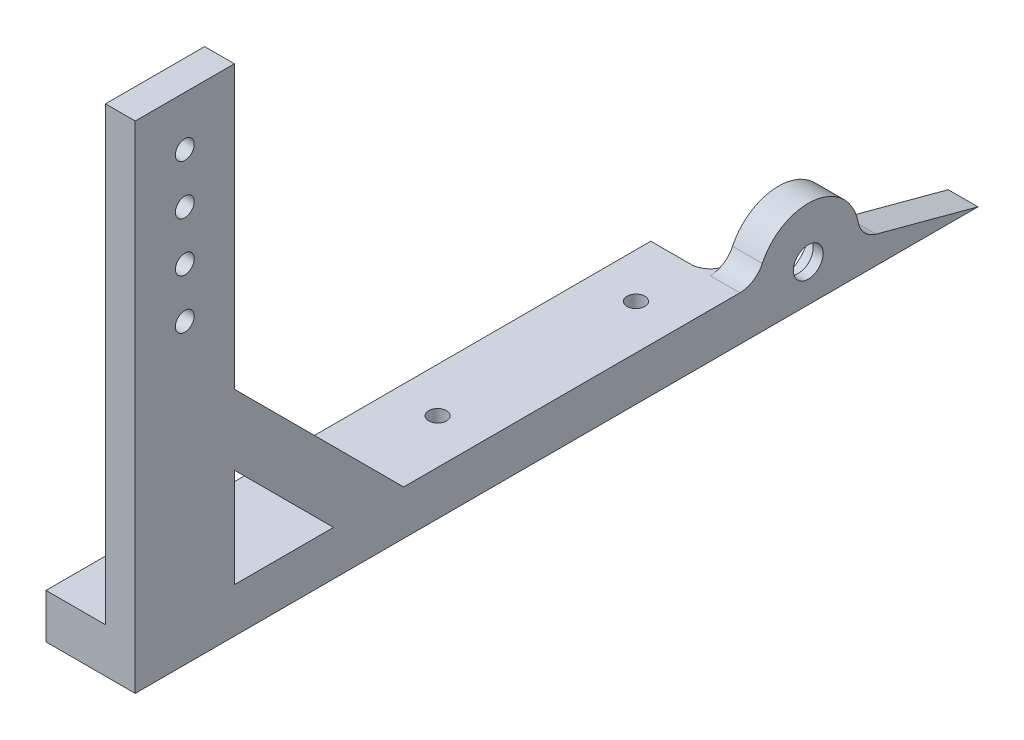
from build123d import *

# Parameters (mm, degrees)
SKETCH1_R           = 7.9375
SKETCH1_R_2         = 2.413
BOSS_EXTRUDE1_DEPTH = 7.62
SKETCH2_R           = 7.9375
SKETCH2_R_2         = 3.81
BOSS_EXTRUDE2_DEPTH = 2.54
SKETCH3_W           = 154.94
SKETCH3_H           = 11.43
BOSS_EXTRUDE3_DEPTH = 15.24
FILLET1_R           = 5.08
BOSS_EXTRUDE4_DEPTH = 7.62
SKETCH5_R           = 2.286
CUT_EXTRUDE1_DEPTH  = 128
CUT_EXTRUDE2_DEPTH  = 6.35


with BuildPart() as part:
    # Sketch1 → Boss-Extrude1 (new body)
    with BuildSketch(Plane(origin=(0, 0, 0), x_dir=(0, 0, -1), z_dir=(1, 0, 0))):
        with BuildLine():
            Line((0, 0), (127, 0))
            Line((127, 0), (100.900837488, 6.993249518))
            ThreePointArc((100.900837488, 6.993249518), (97.889599245, 8.807630529), (96.305117976, 11.94593474))
            ThreePointArc((96.305117976, 11.94593474), (85.15869513, 22.438273755), (71.738889517, 15.073442623))
            ThreePointArc((71.738889517, 15.073442623), (69.395749913, 12.417671245), (65.994583888, 11.43))
            Line((65.994583888, 11.43), (0, 11.43))
            Line((0, 11.43), (-63.5, 11.43))
            Line((-63.5, 11.43), (-63.5, 127))
            Line((-63.5, 127), (-88.9, 127))
            Line((-88.9, 127), (-88.9, 0))
            Line((-88.9, 0), (0, 0))
        make_face()
        with Locations((83.514716058, 9.525)):
            Circle(SKETCH1_R, mode=Mode.SUBTRACT)
        with Locations((-76.2, 114.3)):
            Circle(SKETCH1_R_2, mode=Mode.SUBTRACT)
        with Locations((-76.2, 88.9)):
            Circle(SKETCH1_R_2, mode=Mode.SUBTRACT)
        with Locations((-76.2, 101.6)):
            Circle(SKETCH1_R_2, mode=Mode.SUBTRACT)
        with Locations((-76.2, 76.2)):
            Circle(SKETCH1_R_2, mode=Mode.SUBTRACT)
    extrude(amount=BOSS_EXTRUDE1_DEPTH)

    # Sketch2 → Boss-Extrude2 (add)
    with BuildSketch(Plane(origin=(7.62, 0, 0), x_dir=(0, 0, -1), z_dir=(1, 0, 0))):
        with Locations((83.514716058, 9.525)):
            Circle(SKETCH2_R)
        with Locations((83.514716058, 9.525)):
            Circle(SKETCH2_R_2, mode=Mode.SUBTRACT)
    extrude(amount=-BOSS_EXTRUDE2_DEPTH)

    # Sketch3 → Boss-Extrude3 (add)
    with BuildSketch(Plane.ZY):
        with Locations((11.43, 5.715)):
            Rectangle(SKETCH3_W, SKETCH3_H)
    extrude(amount=BOSS_EXTRUDE3_DEPTH)

    # Fillet1
    fillet1_edges = [part.edges().sort_by_distance(p)[0] for p in [
        (0, 5.715, -66.04),
    ]]
    fillet(fillet1_edges, radius=FILLET1_R)

    # Sketch4 → Boss-Extrude4 (add)
    with BuildSketch(Plane(origin=(7.62, 0, 0), x_dir=(0, 0, -1), z_dir=(1, 0, 0))):
        Polygon((-63.5, 54.790512242), (-20.139487758, 11.43), (-38.1, 11.43), (-63.5, 36.83), align=None)
    extrude(amount=-BOSS_EXTRUDE4_DEPTH)

    # Sketch5 → Cut-Extrude1 (cut, through all)
    with BuildSketch(Plane.XZ):
        with Locations((-3.81, -50.8)):
            Circle(SKETCH5_R)
        with Locations((-3.81, 0)):
            Circle(SKETCH5_R)
    extrude(amount=-CUT_EXTRUDE1_DEPTH, mode=Mode.SUBTRACT)

    # Sketch6 → Cut-Extrude2 (cut)
    with BuildSketch(Plane.XZ):
        Polygon((1.61593783, -50.8), (-1.097031085, -46.101), (-6.522968915, -46.101), (-9.23593783, -50.8), (-6.522968915, -55.499), (-1.097031085, -55.499), align=None)
        Polygon((-1.097031085, -4.699), (1.61593783, 0), (-1.097031085, 4.699), (-6.522968915, 4.699), (-9.23593783, 0), (-6.522968915, -4.699), align=None)
    extrude(amount=-CUT_EXTRUDE2_DEPTH, mode=Mode.SUBTRACT)


solid = part.part
